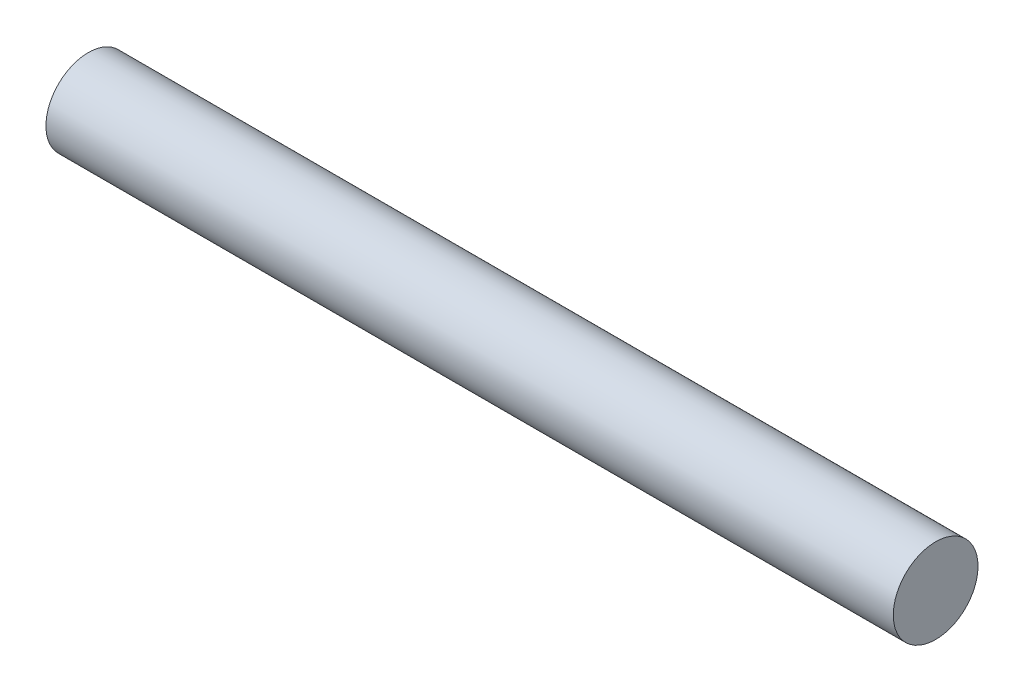
from build123d import *

# Parameters (mm, degrees)
SKETCH1_R           = 2.5
BOSS_EXTRUDE1_DEPTH = 50


with BuildPart() as part:
    # Sketch1 → Boss-Extrude1 (new body)
    with BuildSketch(Plane(origin=(0, 0, 0), x_dir=(0, 0, -1), z_dir=(1, 0, 0))):
        Circle(SKETCH1_R)
    extrude(amount=BOSS_EXTRUDE1_DEPTH)


solid = part.part
